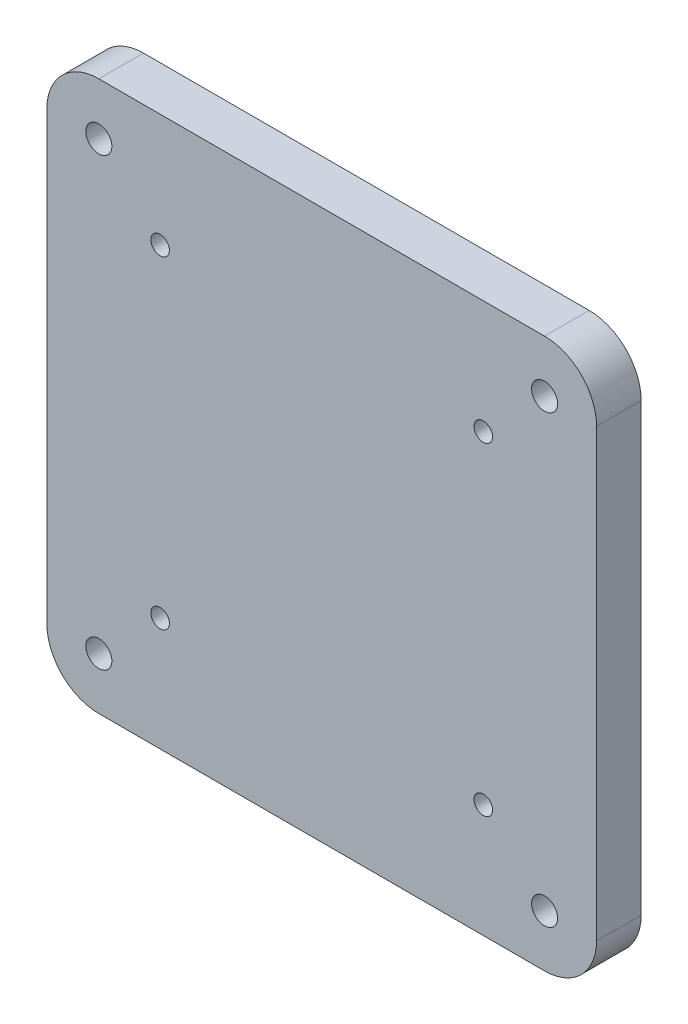
from build123d import *

# Parameters (mm, degrees)
ESQUISSE1_W        = 74
ESQUISSE1_H        = 74
ESQUISSE1_R        = 1.75
ESQUISSE1_R_2      = 1.25
BOSS_EXTRU_1_DEPTH = 6
CONG_1_R           = 7


with BuildPart() as part:
    # Esquisse1 → Boss.-Extru.1 (new body)
    with BuildSketch(Plane.XY):
        Rectangle(ESQUISSE1_W, ESQUISSE1_H)
        with Locations((-30, 30)):
            Circle(ESQUISSE1_R, mode=Mode.SUBTRACT)
        with Locations((-21.75, 21.75)):
            Circle(ESQUISSE1_R_2, mode=Mode.SUBTRACT)
        with Locations((30, 30)):
            Circle(ESQUISSE1_R, mode=Mode.SUBTRACT)
        with Locations((21.75, 21.75)):
            Circle(ESQUISSE1_R_2, mode=Mode.SUBTRACT)
        with Locations((21.75, -21.75)):
            Circle(ESQUISSE1_R_2, mode=Mode.SUBTRACT)
        with Locations((-21.75, -21.75)):
            Circle(ESQUISSE1_R_2, mode=Mode.SUBTRACT)
        with Locations((-30, -30)):
            Circle(ESQUISSE1_R, mode=Mode.SUBTRACT)
        with Locations((30, -30)):
            Circle(ESQUISSE1_R, mode=Mode.SUBTRACT)
    extrude(amount=BOSS_EXTRU_1_DEPTH)

    # Congé1
    cong_1_edges = [part.edges().sort_by_distance(p)[0] for p in [
        (-37, 37, 3),
        (37, 37, 3),
        (37, -37, 3),
        (-37, -37, 3),
    ]]
    fillet(cong_1_edges, radius=CONG_1_R)


solid = part.part
